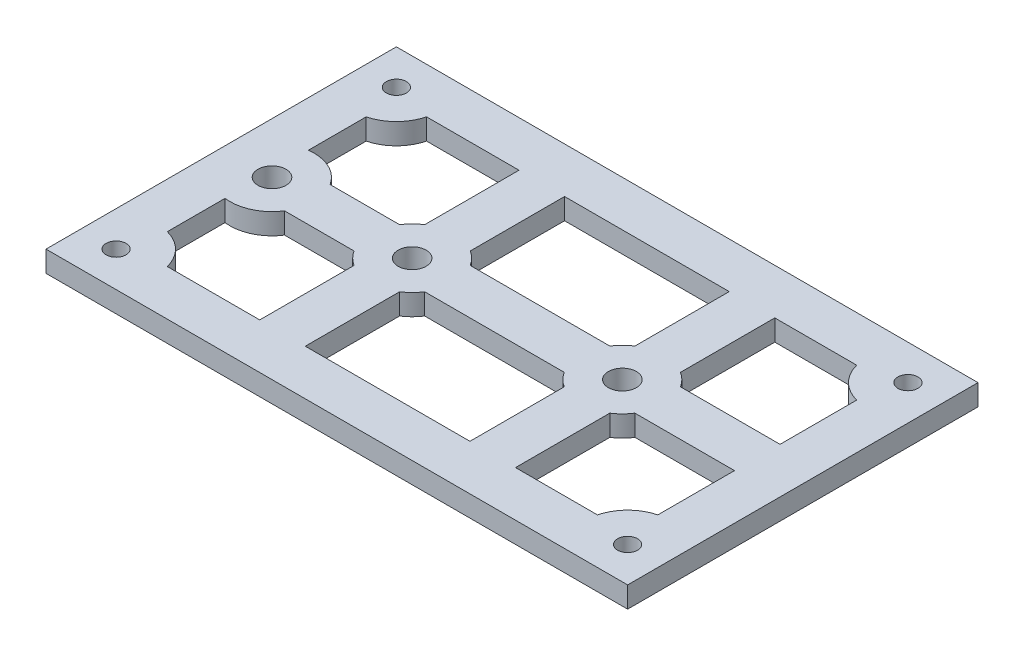
from build123d import *

# Parameters (mm, degrees)
SKETCH1_W            = 83
SKETCH1_H            = 50
BOSS_EXTRUDE1_DEPTH  = 3
SKETCH2_R            = 2
CUT_EXTRUDE1_DEPTH   = 4
SKETCH3_R            = 1.425
CUT_EXTRUDE2_DEPTH   = 4
LPATTERN1_COUNT      = 2
LPATTERN1_PITCH      = 73
LPATTERN1_COUNT_DIR2 = 2
LPATTERN1_PITCH_DIR2 = 40
CUT_EXTRUDE3_DEPTH   = 10


with BuildPart() as part:
    # Sketch1 → Boss-Extrude1 (new body)
    with BuildSketch(Plane(origin=(0, 0, 0), x_dir=(1, 0, 0), z_dir=(0, 1, 0))):
        Rectangle(SKETCH1_W, SKETCH1_H)
    extrude(amount=BOSS_EXTRUDE1_DEPTH)

    # Sketch2 → Cut-Extrude1 (cut, through all)
    with BuildSketch(Plane.XZ):
        with Locations((-34.25, 0)):
            Circle(SKETCH2_R)
        with Locations((-14.25, 0)):
            Circle(SKETCH2_R)
        with Locations((15.75, 0)):
            Circle(SKETCH2_R)
    extrude(amount=-CUT_EXTRUDE1_DEPTH, mode=Mode.SUBTRACT)

    # Sketch3 → Cut-Extrude2 (cut, through all)
    with BuildSketch(Plane.XZ):
        with Locations((-36.5, -20)):
            Circle(SKETCH3_R)
    cut_extrude2 = extrude(amount=-CUT_EXTRUDE2_DEPTH, mode=Mode.SUBTRACT)

    # LPattern1: Cut-Extrude2 2 × 2
    with Locations(*[(i * LPATTERN1_PITCH, 0, j * LPATTERN1_PITCH_DIR2) for i in range(LPATTERN1_COUNT) for j in range(LPATTERN1_COUNT_DIR2) if (i, j) != (0, 0)]):
        add(cut_extrude2, mode=Mode.SUBTRACT)

    # Sketch4 → Cut-Extrude3 (cut)
    with BuildSketch(Plane.XZ):
        with BuildLine():
            Line((0, 18.5), (-11, 18.5))
            Line((-11, 18.5), (-11, 5.04356025))
            ThreePointArc((-11, 5.04356025), (-10.007359313, 4.242640687), (-9.20643975, 3.25))
            Line((-9.20643975, 3.25), (0, 3.25))
            Line((0, 3.25), (10.70643975, 3.25))
            ThreePointArc((10.70643975, 3.25), (11.507359313, 4.242640687), (12.5, 5.04356025))
            Line((12.5, 5.04356025), (12.5, 18.5))
            Line((12.5, 18.5), (0, 18.5))
        make_face()
        with BuildLine():
            Line((0, -3.25), (-9.20643975, -3.25))
            ThreePointArc((-9.20643975, -3.25), (-10.007359313, -4.242640687), (-11, -5.04356025))
            Line((-11, -5.04356025), (-11, -18.5))
            Line((-11, -18.5), (0, -18.5))
            Line((0, -18.5), (12.5, -18.5))
            Line((12.5, -18.5), (12.5, -5.04356025))
            ThreePointArc((12.5, -5.04356025), (11.507359313, -4.242640687), (10.70643975, -3.25))
            Line((10.70643975, -3.25), (0, -3.25))
        make_face()
        with BuildLine():
            Line((-17.5, 18.5), (-30.690524981, 18.5))
            ThreePointArc((-30.690524981, 18.5), (-32.257359313, 15.757359313), (-35, 14.190524981))
            Line((-35, 14.190524981), (-35, 5.95294045))
            ThreePointArc((-35, 5.95294045), (-31.713242882, 5.43735812), (-29.20643975, 3.25))
            Line((-29.20643975, 3.25), (-19.29356025, 3.25))
            ThreePointArc((-19.29356025, 3.25), (-18.492640687, 4.242640687), (-17.5, 5.04356025))
            Line((-17.5, 5.04356025), (-17.5, 18.5))
        make_face()
        with BuildLine():
            Line((-19.29356025, -3.25), (-29.20643975, -3.25))
            ThreePointArc((-29.20643975, -3.25), (-31.713242882, -5.43735812), (-35, -5.95294045))
            Line((-35, -5.95294045), (-35, -14.190524981))
            ThreePointArc((-35, -14.190524981), (-32.257359313, -15.757359313), (-30.690524981, -18.5))
            Line((-30.690524981, -18.5), (-17.5, -18.5))
            Line((-17.5, -18.5), (-17.5, -5.04356025))
            ThreePointArc((-17.5, -5.04356025), (-18.492640687, -4.242640687), (-19.29356025, -3.25))
        make_face()
        with BuildLine():
            Line((20.79356025, 3.25), (35, 3.25))
            Line((35, 3.25), (35, 14.190524981))
            ThreePointArc((35, 14.190524981), (32.257359313, 15.757359313), (30.690524981, 18.5))
            Line((30.690524981, 18.5), (19, 18.5))
            Line((19, 18.5), (19, 5.04356025))
            ThreePointArc((19, 5.04356025), (19.992640687, 4.242640687), (20.79356025, 3.25))
        make_face()
        with BuildLine():
            Line((20.79356025, -3.25), (35, -3.25))
            Line((35, -3.25), (35, -14.190524981))
            ThreePointArc((35, -14.190524981), (32.257359313, -15.757359313), (30.690524981, -18.5))
            Line((30.690524981, -18.5), (19, -18.5))
            Line((19, -18.5), (19, -5.04356025))
            ThreePointArc((19, -5.04356025), (19.992640687, -4.242640687), (20.79356025, -3.25))
        make_face()
    extrude(amount=-CUT_EXTRUDE3_DEPTH, mode=Mode.SUBTRACT)


solid = part.part
